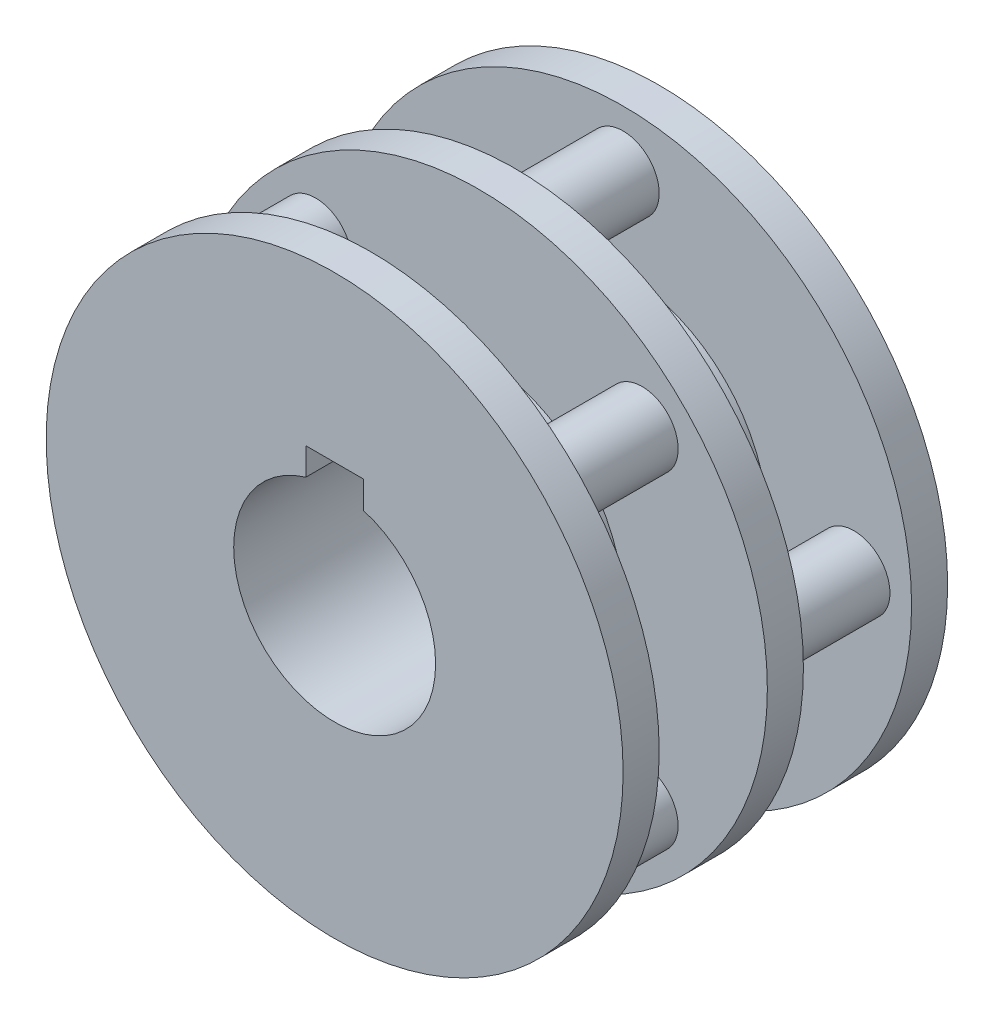
from build123d import *

# Parameters (mm, degrees)
SKETCH_1_R          = 40
EXTRUDE_1_DEPTH     = 5
SKETCH_2_R          = 5
EXTRUDE_2_DEPTH     = 15
SKETCH_3_R          = 40
EXTRUDE_3_DEPTH     = 5
SKETCH_4_R          = 5
EXTRUDE_4_DEPTH     = 15
SKETCH_5_R          = 40
EXTRUDE_5_DEPTH     = 5
SKETCH_6_R          = 20
EXTRUDE_6_DEPTH     = 35
SKETCH_7_R          = 14
CUT_EXTRUDE_1_DEPTH = 57
CUT_EXTRUDE_2_DEPTH = 57


with BuildPart() as part:
    # 草图1 → 凸台-拉伸1 (new body)
    with BuildSketch(Plane.XY):
        Circle(SKETCH_1_R)
    extrude(amount=EXTRUDE_1_DEPTH)

    # 草图2 → 凸台-拉伸2 (add)
    with BuildSketch(Plane.XY.offset(5)):
        with Locations((32, 0)):
            Circle(SKETCH_2_R)
        with Locations((0, -32)):
            Circle(SKETCH_2_R)
        with Locations((-32, 0)):
            Circle(SKETCH_2_R)
        with Locations((0, 32)):
            Circle(SKETCH_2_R)
    extrude(amount=EXTRUDE_2_DEPTH)

    # 草图3 → 凸台-拉伸3 (add)
    with BuildSketch(Plane.XY.offset(20)):
        Circle(SKETCH_3_R)
    extrude(amount=EXTRUDE_3_DEPTH)

    # 草图4 → 凸台-拉伸4 (add)
    with BuildSketch(Plane.XY.offset(25)):
        with Locations((22.627416998, -22.627416998)):
            Circle(SKETCH_4_R)
        with Locations((-22.627416998, -22.627416998)):
            Circle(SKETCH_4_R)
        with Locations((-22.627416998, 22.627416998)):
            Circle(SKETCH_4_R)
        with Locations((22.627416998, 22.627416998)):
            Circle(SKETCH_4_R)
    extrude(amount=EXTRUDE_4_DEPTH)

    # 草图5 → 凸台-拉伸5 (add)
    with BuildSketch(Plane.XY.offset(40)):
        Circle(SKETCH_5_R)
    extrude(amount=EXTRUDE_5_DEPTH)

    # 草图6 → 凸台-拉伸6 (add)
    with BuildSketch(Plane.XY.offset(5)):
        Circle(SKETCH_6_R)
    extrude(amount=EXTRUDE_6_DEPTH)

    # 草图7 → 切除-拉伸1 (cut)
    with BuildSketch(Plane.XY.offset(45)):
        Circle(SKETCH_7_R)
    extrude(amount=-CUT_EXTRUDE_1_DEPTH, mode=Mode.SUBTRACT)

    # 草图8 → 切除-拉伸2 (cut)
    with BuildSketch(Plane.XY.offset(45)):
        Polygon((-4, 14), (-4, 9.394877301), (4, 9.394877301), (4, 14), (4, 17.2), (-4, 17.2), align=None)
    extrude(amount=-CUT_EXTRUDE_2_DEPTH, mode=Mode.SUBTRACT)


solid = part.part
